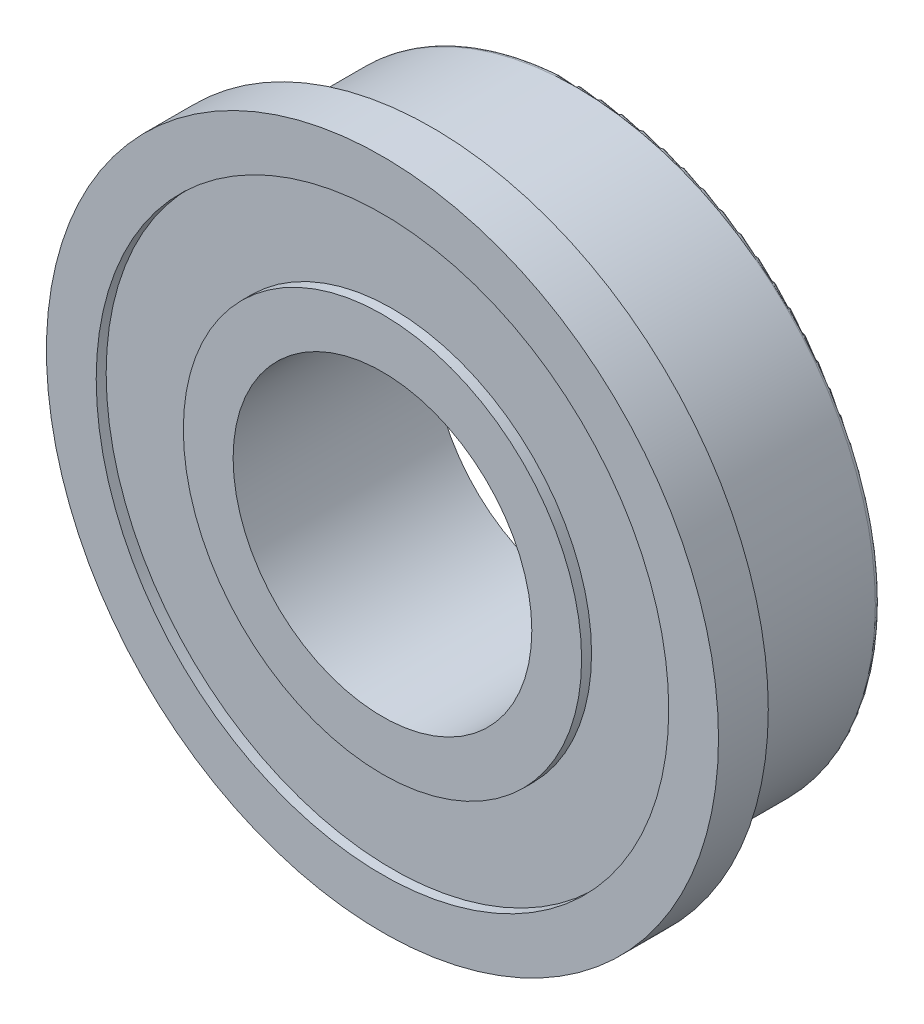
from build123d import *

# Parameters (mm, degrees)
SKETCH_1_R          = 6
EXTRUDE_1_DEPTH     = 4
SKETCH_2_R          = 6.75
EXTRUDE_2_DEPTH     = 1
SKETCH_3_R          = 3
CUT_EXTRUDE_1_DEPTH = 5
SKETCH_4_R          = 5
SKETCH_4_R_2        = 4
CUT_EXTRUDE_2_DEPTH = 0.2
SKETCH_5_R          = 5.75
SKETCH_5_R_2        = 4
CUT_EXTRUDE_3_DEPTH = 0.2
FILLET_1_R          = 0.1


with BuildPart() as part:
    # 草圖1 → 填料-伸長1 (new body)
    with BuildSketch(Plane.XY):
        Circle(SKETCH_1_R)
    extrude(amount=EXTRUDE_1_DEPTH)

    # 草圖2 → 填料-伸長2 (add)
    with BuildSketch(Plane.XY.offset(4)):
        Circle(SKETCH_2_R)
    extrude(amount=-EXTRUDE_2_DEPTH)

    # 草圖3 → 除料-伸長1 (cut, through all)
    with BuildSketch(Plane(origin=(0, 0, 0), x_dir=(-1, 0, 0), z_dir=(0, 0, -1))):
        Circle(SKETCH_3_R)
    extrude(amount=-CUT_EXTRUDE_1_DEPTH, mode=Mode.SUBTRACT)

    # 草圖4 → 除料-伸長2 (cut)
    with BuildSketch(Plane(origin=(0, 0, 0), x_dir=(-1, 0, 0), z_dir=(0, 0, -1))):
        Circle(SKETCH_4_R)
        Circle(SKETCH_4_R_2, mode=Mode.SUBTRACT)
    extrude(amount=-CUT_EXTRUDE_2_DEPTH, mode=Mode.SUBTRACT)

    # 草圖5 → 除料-伸長3 (cut)
    with BuildSketch(Plane.XY.offset(4)):
        Circle(SKETCH_5_R)
        Circle(SKETCH_5_R_2, mode=Mode.SUBTRACT)
    extrude(amount=-CUT_EXTRUDE_3_DEPTH, mode=Mode.SUBTRACT)

    # 圓角1
    fillet_1_edges = [part.edges().sort_by_distance(p)[0] for p in [
        (-6, 0, 0),
    ]]
    fillet(fillet_1_edges, radius=FILLET_1_R)


solid = part.part
